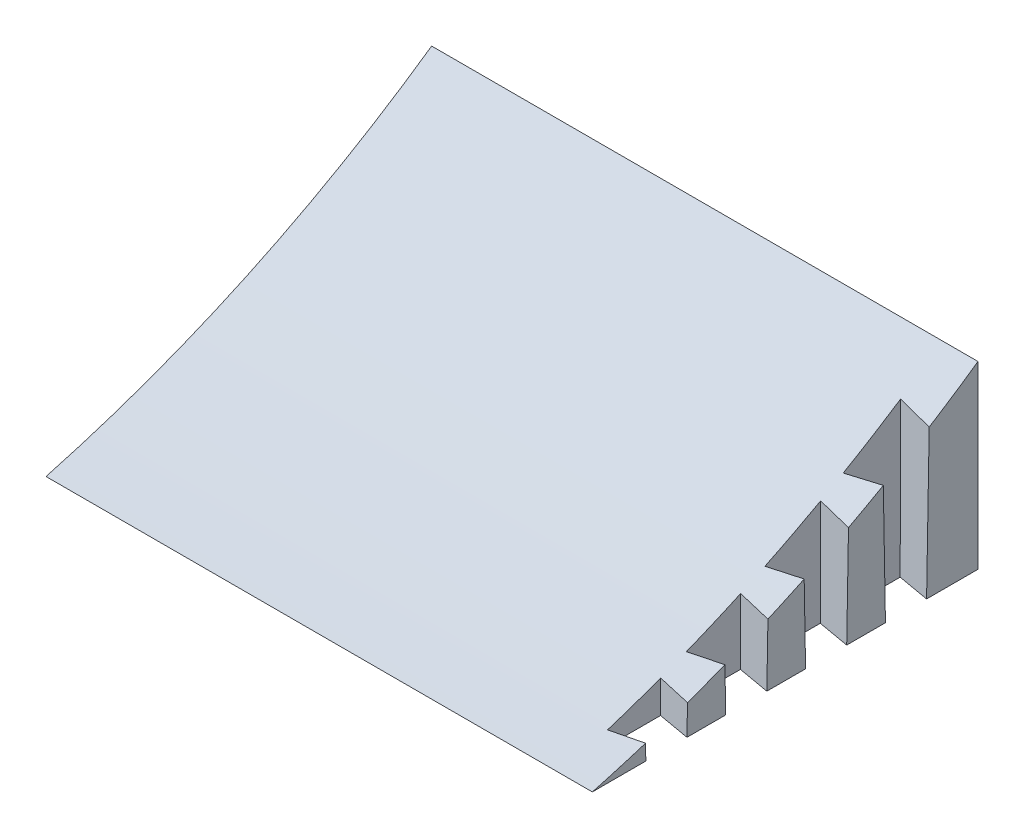
from build123d import *

# Parameters (mm, degrees)
BOSS_EXTRUDE1_DEPTH = 134.9375
SKETCH4_W           = 25.4
SKETCH4_H           = 19.05
CUT_EXTRUDE1_DEPTH  = 6.35
SKETCH5_R           = 2.921
CUT_EXTRUDE2_DEPTH  = 25.4
CUT_EXTRUDE3_DEPTH  = 38.1
CUT_EXTRUDE3_TAPER  = -1


with BuildPart() as part:
    # Sketch3 → Boss-Extrude1 (new body)
    with BuildSketch(Plane(origin=(0, 0, 0), x_dir=(0, 0, -1), z_dir=(1, 0, 0))):
        with BuildLine():
            Line((0, 0), (95.25, 0))
            Line((95.25, 0), (95.25, 44.45))
            ThreePointArc((95.25, 44.45), (49.555547135, 18.088113282), (0, 0))
        make_face()
    extrude(amount=BOSS_EXTRUDE1_DEPTH)

    # Sketch4 → Cut-Extrude1 (cut)
    with BuildSketch(Plane.ZY):
        with Locations((-82.55, 17.145)):
            Rectangle(SKETCH4_W, SKETCH4_H)
    extrude(amount=-CUT_EXTRUDE1_DEPTH, mode=Mode.SUBTRACT)

    # Sketch5 → Cut-Extrude2 (cut)
    with BuildSketch(Plane.ZY.offset(-6.35)):
        with Locations((-82.55, 17.145)):
            Circle(SKETCH5_R)
    extrude(amount=-CUT_EXTRUDE2_DEPTH, mode=Mode.SUBTRACT)

    # Sketch6 → Cut-Extrude3 (cut)
    with BuildSketch(Plane.XZ):
        Polygon((134.9375, -82.55), (134.9375, -72.39), (127.014719298, -70.993), (127.014719298, -83.947), align=None)
        Polygon((134.9375, -62.822666667), (134.9375, -52.662666667), (127.014719298, -51.265666667), (127.014719298, -64.219666667), align=None)
        Polygon((134.9375, -43.095333333), (134.9375, -32.935333333), (127.014719298, -31.538333333), (127.014719298, -44.492333333), align=None)
        Polygon((134.9375, -23.368), (134.9375, -13.208), (127.014719298, -11.811), (127.014719298, -24.765), align=None)
    extrude(amount=-CUT_EXTRUDE3_DEPTH, taper=CUT_EXTRUDE3_TAPER, mode=Mode.SUBTRACT)


solid = part.part
